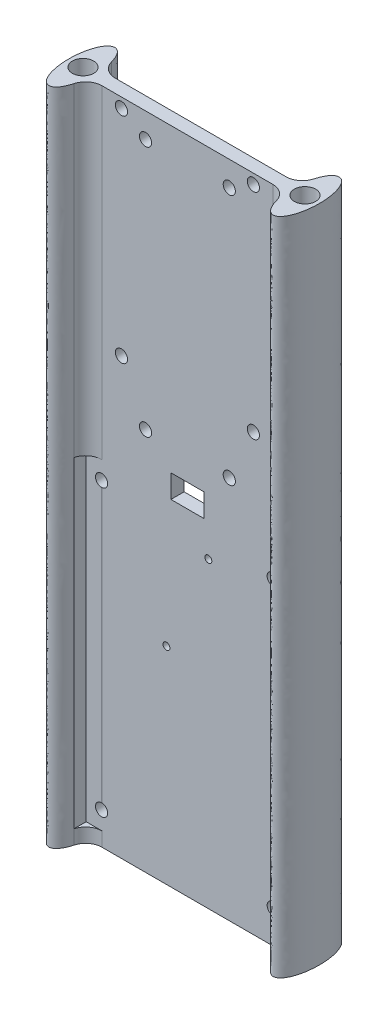
from build123d import *

# Parameters (mm, degrees)
SKETCH1_R               = 3.2385
BOSS_EXTRUDE1_DEPTH     = 200
FILLET1_R               = 5
CUT_EXTRUDE1_DEPTH      = 9.0000001
CUT_EXTRUDE1_DEPTH_BACK = 13.0000001
SKETCH2_R               = 1.85
SKETCH2_W               = 10
SKETCH2_H               = 7
CUT_EXTRUDE2_DEPTH      = 9.0000001
CUT_EXTRUDE2_DEPTH_BACK = 13.0000001
CUT_EXTRUDE3_DEPTH      = 30
SKETCH4_R               = 1.05
CUT_EXTRUDE4_DEPTH      = 10


with BuildPart() as part:
    # Sketch1 → Boss-Extrude1 (new body)
    with BuildSketch(Plane(origin=(0, 0, 0), x_dir=(1, 0, 0), z_dir=(0, 1, 0))):
        with BuildLine():
            add(Edge.make_bspline(
                [(30.080816412, -2), (30.734013676, -10), (34, -10)],
                knots=[4.913746901, 4.913746901, 4.913746901, 6.283185307, 6.283185307, 6.283185307], degree=2, weights=[1, 0.774596669, 1]))
            add(Edge.make_bspline(
                [(34, -10), (42.429964119, -10), (37.098386677, 6.32455532), (31.766809235, 22.649110641), (30.080816412, 2)],
                knots=[0, 0, 0, 2.25551553, 2.25551553, 4.51103106, 4.51103106, 4.51103106], degree=2, weights=[1, 0.428686638, 1, 0.428686638, 1]))
            Line((30.080816412, 2), (-30.080816412, 2))
            add(Edge.make_bspline(
                [(-30.080816412, 2), (-31.766809235, 22.649110641), (-37.098386677, 6.32455532), (-42.429964119, -10), (-34, -10)],
                knots=[1.772154248, 1.772154248, 1.772154248, 4.027669777, 4.027669777, 6.283185307, 6.283185307, 6.283185307], degree=2, weights=[1, 0.428686638, 1, 0.428686638, 1]))
            add(Edge.make_bspline(
                [(-34, -10), (-30.734013676, -10), (-30.080816412, -2)],
                knots=[0, 0, 0, 1.369438406, 1.369438406, 1.369438406], degree=2, weights=[1, 0.774596669, 1]))
            Line((-30.080816412, -2), (30.080816412, -2))
        make_face()
        with Locations((33.655, 0)):
            Circle(SKETCH1_R, mode=Mode.SUBTRACT)
        with Locations((-33.655, 0)):
            Circle(SKETCH1_R, mode=Mode.SUBTRACT)
    extrude(amount=BOSS_EXTRUDE1_DEPTH)

    # Fillet1
    fillet1_edges = [part.edges().sort_by_distance(p)[0] for p in [
        (30.080816412, 100, -2),
        (30.080816412, 100, 2),
        (-30.080816412, 100, -2),
        (-30.080816412, 100, 2),
    ]]
    fillet(fillet1_edges, radius=FILLET1_R)

    # Sketch3 → Cut-Extrude1 (cut, two sides)
    with BuildSketch(Plane(origin=(0, 0, -2), x_dir=(-1, 0, 0), z_dir=(0, 0, -1))) as cut_extrude1_sk:
        with BuildLine():
            ThreePointArc((-18.15, 197), (-21.308147545, 198.308147545), (-20, 195.15))
            Line((-20, 195.15), (-20, 197))
            Line((-20, 197), (-18.15, 197))
        make_face()
        with BuildLine():
            Line((-20, 197), (-20, 195.15))
            ThreePointArc((-20, 195.15), (-18.691852455, 195.691852455), (-18.15, 197))
            Line((-18.15, 197), (-20, 197))
        make_face()
        with BuildLine():
            ThreePointArc((18.15, 197), (18.691852455, 195.691852455), (20, 195.15))
            Line((20, 195.15), (20, 197))
            Line((20, 197), (18.15, 197))
        make_face()
        with BuildLine():
            Line((20, 197), (20, 195.15))
            ThreePointArc((20, 195.15), (21.308147545, 195.691852455), (21.85, 197))
            ThreePointArc((21.85, 197), (20, 198.85), (18.15, 197))
            Line((18.15, 197), (20, 197))
        make_face()
        with BuildLine():
            ThreePointArc((-20, 133.85), (-21.308147545, 130.691852455), (-18.15, 132))
            Line((-18.15, 132), (-20, 132))
            Line((-20, 132), (-20, 133.85))
        make_face()
        with BuildLine():
            Line((-20, 132), (-18.15, 132))
            ThreePointArc((-18.15, 132), (-18.691852455, 133.308147545), (-20, 133.85))
            Line((-20, 133.85), (-20, 132))
        make_face()
        with BuildLine():
            ThreePointArc((20, 133.85), (18.691852455, 133.308147545), (18.15, 132))
            Line((18.15, 132), (20, 132))
            Line((20, 132), (20, 133.85))
        make_face()
        with BuildLine():
            Line((20, 132), (18.15, 132))
            ThreePointArc((18.15, 132), (20, 130.15), (21.85, 132))
            ThreePointArc((21.85, 132), (21.308147545, 133.308147545), (20, 133.85))
            Line((20, 133.85), (20, 132))
        make_face()
    extrude(amount=CUT_EXTRUDE1_DEPTH, mode=Mode.SUBTRACT)
    extrude(cut_extrude1_sk.sketch, amount=-CUT_EXTRUDE1_DEPTH_BACK, mode=Mode.SUBTRACT)

    # Sketch2 → Cut-Extrude2 (cut, two sides)
    with BuildSketch(Plane.XY.offset(2)) as cut_extrude2_sk:
        with Locations((-12.7, 192.5)):
            Circle(SKETCH2_R)
        with Locations((12.7, 192.5)):
            Circle(SKETCH2_R)
        with Locations((-12.7, 116.3)):
            Circle(SKETCH2_R)
        with Locations((12.7, 116.3)):
            Circle(SKETCH2_R)
        with Locations((0, 105.3)):
            Rectangle(SKETCH2_W, SKETCH2_H)
        with Locations((-26.03, 9.8)):
            Circle(SKETCH2_R)
        with Locations((26.03, 9.8)):
            Circle(SKETCH2_R)
        with Locations((-26.03, 96.3)):
            Circle(SKETCH2_R)
        with Locations((26.03, 96.3)):
            Circle(SKETCH2_R)
    extrude(amount=CUT_EXTRUDE2_DEPTH, mode=Mode.SUBTRACT)
    extrude(cut_extrude2_sk.sketch, amount=-CUT_EXTRUDE2_DEPTH_BACK, mode=Mode.SUBTRACT)

    # Sketch2_3 → Cut-Extrude3 (cut)
    with BuildSketch(Plane.XY.offset(2)):
        with BuildLine():
            Line((30.70569336, 101.8), (25.885263071, 101.8))
            Line((25.885263071, 101.8), (25.885263071, 98.144329477))
            ThreePointArc((25.885263071, 98.144329477), (27.285933255, 97.658356234), (27.88, 96.3))
            ThreePointArc((27.88, 96.3), (27.338147545, 94.991852455), (26.03, 94.45))
            Line((26.03, 94.45), (26.03, 11.65))
            ThreePointArc((26.03, 11.65), (27.338147545, 11.108147545), (27.88, 9.8))
            ThreePointArc((27.88, 9.8), (27.285933255, 8.441643766), (25.885263071, 7.955670523))
            Line((25.885263071, 7.955670523), (25.885263071, 4.3))
            Line((25.885263071, 4.3), (30.70569336, 4.3))
            Line((30.70569336, 4.3), (30.70569336, 101.8))
        make_face()
        with BuildLine():
            Line((-25.885263071, 98.144329477), (-25.885263071, 101.8))
            Line((-25.885263071, 101.8), (-30.70569336, 101.8))
            Line((-30.70569336, 101.8), (-30.70569336, 4.3))
            Line((-30.70569336, 4.3), (-25.885263071, 4.3))
            Line((-25.885263071, 4.3), (-25.885263071, 7.955670523))
            ThreePointArc((-25.885263071, 7.955670523), (-27.878581826, 9.727576017), (-26.03, 11.65))
            Line((-26.03, 11.65), (-26.03, 94.45))
            ThreePointArc((-26.03, 94.45), (-27.878581826, 96.372423983), (-25.885263071, 98.144329477))
        make_face()
    extrude(amount=CUT_EXTRUDE3_DEPTH, mode=Mode.SUBTRACT)

    # Sketch4 → Cut-Extrude4 (cut)
    with BuildSketch(Plane(origin=(0, 0, -2), x_dir=(-1, 0, 0), z_dir=(0, 0, -1))):
        with Locations((-6.35, 91.8)):
            Circle(SKETCH4_R)
        with Locations((6.35, 62.59)):
            Circle(SKETCH4_R)
    extrude(amount=-CUT_EXTRUDE4_DEPTH, mode=Mode.SUBTRACT)


solid = part.part
